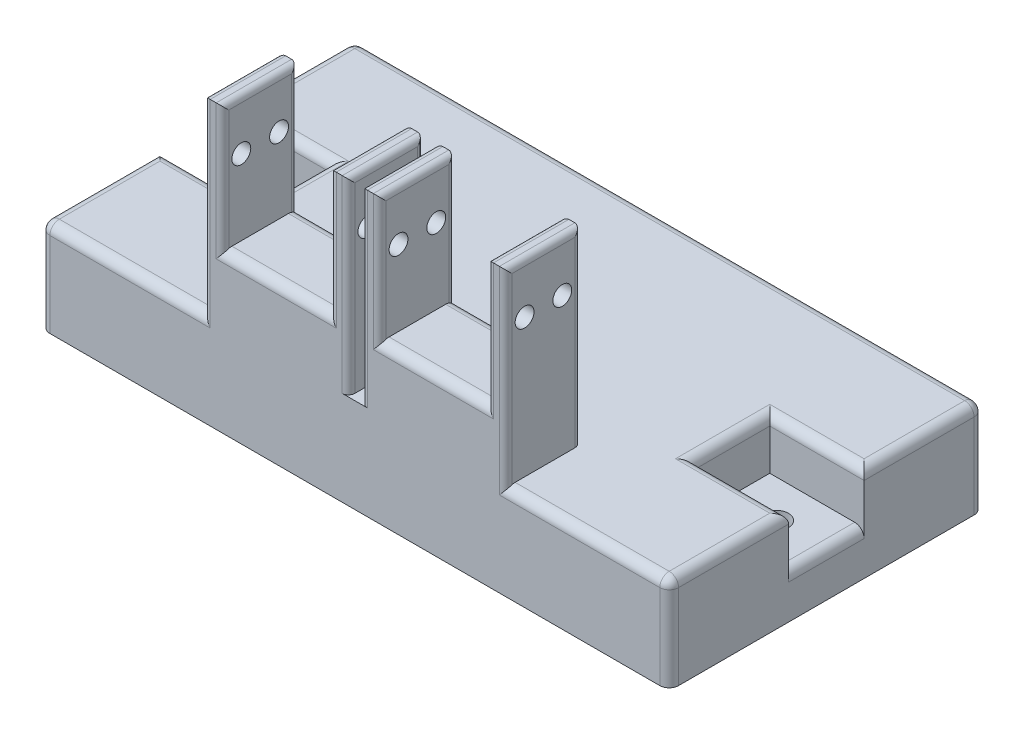
from build123d import *

# Parameters (mm, degrees)
SKETCH1_W           = 100
SKETCH1_H           = 50
BOSS_EXTRUDE1_DEPTH = 15
SKETCH2_W           = 30
SKETCH2_H           = 12
CUT_EXTRUDE1_DEPTH  = 8
SKETCH7_W           = 23
SKETCH7_H           = 12
BOSS_EXTRUDE2_DEPTH = 10
SKETCH8_W           = 2.95
SKETCH8_H           = 12
BOSS_EXTRUDE3_DEPTH = 20
SKETCH10_R          = 1.5
CUT_EXTRUDE2_DEPTH  = 50
FILLET1_R           = 1.5
FILLET2_R           = 1
SKETCH11_R          = 1.975
CUT_EXTRUDE3_DEPTH  = 20
SKETCH12_R          = 1.975
CUT_EXTRUDE4_DEPTH  = 20


with BuildPart() as part:
    # Sketch1 → Boss-Extrude1 (new body)
    with BuildSketch(Plane(origin=(0, 0, 0), x_dir=(1, 0, 0), z_dir=(0, 1, 0))):
        Rectangle(SKETCH1_W, SKETCH1_H)
    extrude(amount=BOSS_EXTRUDE1_DEPTH)

    # Sketch2 → Cut-Extrude1 (cut)
    with BuildSketch(Plane(origin=(0, 15, 0), x_dir=(1, 0, 0), z_dir=(0, 1, 0))):
        with Locations((-50, 0)):
            Rectangle(SKETCH2_W, SKETCH2_H)
        with Locations((50, 0)):
            Rectangle(SKETCH2_W, SKETCH2_H)
    extrude(amount=-CUT_EXTRUDE1_DEPTH, mode=Mode.SUBTRACT)

    # Sketch7 → Boss-Extrude2 (add)
    with BuildSketch(Plane(origin=(0, 15, 0), x_dir=(1, 0, 0), z_dir=(0, 1, 0))):
        with Locations((12.5, -19)):
            Rectangle(SKETCH7_W, SKETCH7_H)
    boss_extrude2 = extrude(amount=BOSS_EXTRUDE2_DEPTH)

    # Sketch8 → Boss-Extrude3 (add)
    with BuildSketch(Plane(origin=(0, 25, 0), x_dir=(1, 0, 0), z_dir=(0, 1, 0))):
        with Locations((2.475, -19)):
            Rectangle(SKETCH8_W, SKETCH8_H)
        with Locations((22.525, -19)):
            Rectangle(SKETCH8_W, SKETCH8_H)
    boss_extrude3 = extrude(amount=BOSS_EXTRUDE3_DEPTH)

    # Sketch10 → Cut-Extrude2 (cut, through all)
    with BuildSketch(Plane.ZY.offset(-1)):
        with Locations((16, 37)):
            Circle(SKETCH10_R)
        with Locations((22, 37)):
            Circle(SKETCH10_R)
    cut_extrude2 = extrude(amount=-CUT_EXTRUDE2_DEPTH, mode=Mode.SUBTRACT)

    # Mirror1: Boss-Extrude2, Boss-Extrude3, Cut-Extrude2 across plane
    add(boss_extrude2.mirror(Plane(origin=(0, 0, 0), x_dir=(0, 0, 1), z_dir=(1, 0, 0))))
    add(boss_extrude3.mirror(Plane(origin=(0, 0, 0), x_dir=(0, 0, 1), z_dir=(1, 0, 0))))
    add(cut_extrude2.mirror(Plane(origin=(0, 0, 0), x_dir=(0, 0, 1), z_dir=(1, 0, 0))), mode=Mode.SUBTRACT)

    # Fillet1
    fillet1_edges = [part.edges().sort_by_distance(p)[0] for p in [
        (-12.5, 25, 25),
        (-12.5, 25, 13),
        (-50, 15, -15.5),
        (50, 15, -15.5),
        (-50, 15, 15.5),
        (42.5, 15, -6),
        (-37, 15, 25),
        (-42.5, 15, 6),
        (-50, 7, 0),
        (50, 7, 0),
        (-35, 15, 0),
        (-42.5, 15, -6),
        (42.5, 15, 6),
        (35, 15, 0),
        (50, 15, 15.5),
        (37, 15, 25),
        (12.5, 25, 25),
        (12.5, 25, 13),
        (50, 7.5, 25),
        (-50, 7.5, 25),
        (-50, 7.5, -25),
        (50, 7.5, -25),
        (0, 15, -25),
    ]]
    fillet(fillet1_edges, radius=FILLET1_R)

    # Fillet2
    fillet2_edges = [part.edges().sort_by_distance(p)[0] for p in [
        (-24, 30, 13),
        (-24, 30, 25),
        (-1, 30, 25),
        (-1, 30, 13),
        (-3.95, 45, 19),
        (-3.95, 35, 13),
        (-3.95, 35, 25),
        (-1, 45, 19),
        (-21.05, 35, 13),
        (-24, 45, 19),
        (-21.05, 45, 19),
        (-21.05, 35, 25),
        (24, 30, 25),
        (24, 30, 13),
        (1, 30, 13),
        (1, 30, 25),
        (3.95, 35, 13),
        (3.95, 35, 25),
        (1, 45, 19),
        (3.95, 45, 19),
        (21.05, 35, 13),
        (21.05, 35, 25),
        (21.05, 45, 19),
        (24, 45, 19),
    ]]
    fillet(fillet2_edges, radius=FILLET2_R)

    # Sketch11 → Cut-Extrude3 (cut)
    with BuildSketch(Plane(origin=(0, 7, 0), x_dir=(1, 0, 0), z_dir=(0, 1, 0))):
        with Locations((42, 0)):
            Circle(SKETCH11_R)
    extrude(amount=-CUT_EXTRUDE3_DEPTH, mode=Mode.SUBTRACT)

    # Sketch12 → Cut-Extrude4 (cut)
    with BuildSketch(Plane(origin=(0, 7, 0), x_dir=(1, 0, 0), z_dir=(0, 1, 0))):
        with Locations((-42, 0)):
            Circle(SKETCH12_R)
    extrude(amount=-CUT_EXTRUDE4_DEPTH, mode=Mode.SUBTRACT)


solid = part.part
